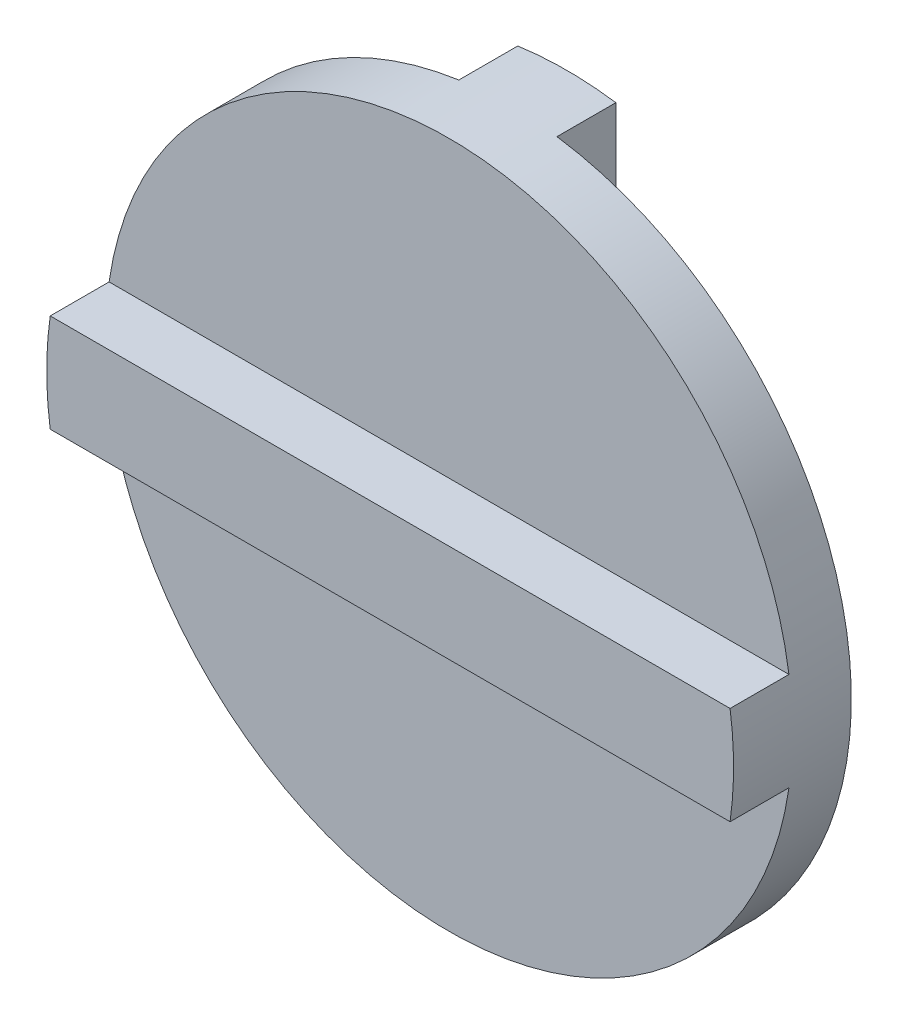
from build123d import *

# Parameters (mm, degrees)
SKETCH1_R           = 17.5
BOSS_EXTRUDE1_DEPTH = 3
BOSS_EXTRUDE2_DEPTH = 3
BOSS_EXTRUDE3_DEPTH = 3


with BuildPart() as part:
    # Sketch1 → Boss-Extrude1 (new body)
    with BuildSketch(Plane.XY):
        Circle(SKETCH1_R)
    extrude(amount=BOSS_EXTRUDE1_DEPTH)

    # Sketch2 → Boss-Extrude2 (add)
    with BuildSketch(Plane.XY.offset(3)):
        with BuildLine():
            Line((0, 2.5), (-17.320508076, 2.5))
            ThreePointArc((-17.320508076, 2.5), (-17.5, 0), (-17.320508076, -2.5))
            Line((-17.320508076, -2.5), (0, -2.5))
            Line((0, -2.5), (0, 2.5))
        make_face()
        with BuildLine():
            Line((17.320508076, 2.5), (0, 2.5))
            Line((0, 2.5), (0, -2.5))
            Line((0, -2.5), (17.320508076, -2.5))
            ThreePointArc((17.320508076, -2.5), (17.45506934, -1.253217594), (17.5, 0))
            ThreePointArc((17.5, 0), (17.45506934, 1.253217594), (17.320508076, 2.5))
        make_face()
    extrude(amount=BOSS_EXTRUDE2_DEPTH)

    # Sketch3 → Boss-Extrude3 (add)
    with BuildSketch(Plane(origin=(0, 0, 0), x_dir=(-1, 0, 0), z_dir=(0, 0, -1))):
        with BuildLine():
            ThreePointArc((0, 17.5), (-1.253217594, 17.45506934), (-2.5, 17.320508076))
            Line((-2.5, 17.320508076), (-2.5, -17.320508076))
            ThreePointArc((-2.5, -17.320508076), (-1.253217594, -17.45506934), (0, -17.5))
            Line((0, -17.5), (0, 17.5))
        make_face()
        with BuildLine():
            ThreePointArc((2.5, 17.320508076), (1.253217594, 17.45506934), (0, 17.5))
            Line((0, 17.5), (0, -17.5))
            ThreePointArc((0, -17.5), (1.253217594, -17.45506934), (2.5, -17.320508076))
            Line((2.5, -17.320508076), (2.5, 17.320508076))
        make_face()
    extrude(amount=BOSS_EXTRUDE3_DEPTH)


solid = part.part
